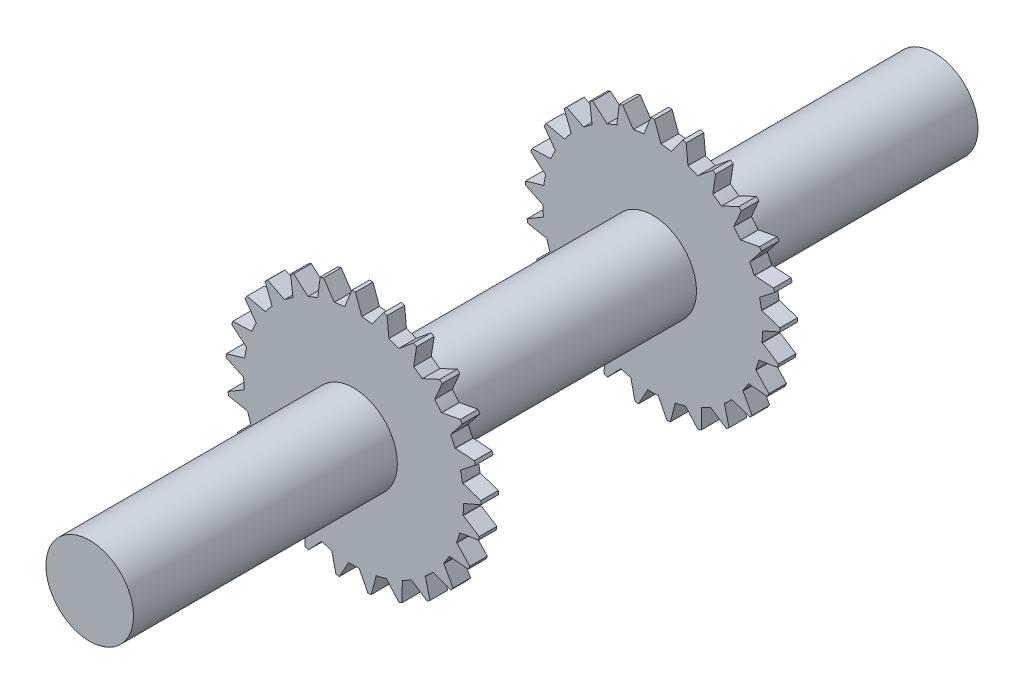
from build123d import *

# Parameters (mm, degrees)
SKETCH1_R             = 24.875
BOSS_EXTRUDE1_DEPTH   = 480
SKETCH2_R             = 62.5
BOSS_EXTRUDE2_DEPTH   = 10
BOSS_EXTRUDE3_DEPTH   = 10
CIRPATTERN2_COUNT     = 25
MIRROR1_COPY_1_DEPTH  = 10
MIRROR1_COPY_2_DEPTH  = 10
MIRROR1_COPY_3_DEPTH  = 10
MIRROR1_COPY_4_DEPTH  = 10
MIRROR1_COPY_5_DEPTH  = 10
MIRROR1_COPY_6_DEPTH  = 10
MIRROR1_COPY_7_DEPTH  = 10
MIRROR1_COPY_8_DEPTH  = 10
MIRROR1_COPY_9_DEPTH  = 10
MIRROR1_COPY_10_DEPTH = 10
MIRROR1_COPY_11_DEPTH = 10
MIRROR1_COPY_12_DEPTH = 10
MIRROR1_COPY_13_DEPTH = 10
MIRROR1_COPY_14_DEPTH = 10
MIRROR1_COPY_15_DEPTH = 10
MIRROR1_COPY_16_DEPTH = 10
MIRROR1_COPY_17_DEPTH = 10
MIRROR1_COPY_18_DEPTH = 10
MIRROR1_COPY_19_DEPTH = 10
MIRROR1_COPY_20_DEPTH = 10
MIRROR1_COPY_21_DEPTH = 10
MIRROR1_COPY_22_DEPTH = 10
MIRROR1_COPY_23_DEPTH = 10
MIRROR1_COPY_24_DEPTH = 10


with BuildPart() as part:
    # Sketch1 → Boss-Extrude1 (new body)
    with BuildSketch(Plane.XY):
        Circle(SKETCH1_R)
    extrude(amount=BOSS_EXTRUDE1_DEPTH)

    # Sketch2 → Boss-Extrude2 (add)
    with BuildSketch(Plane.XY.offset(330)):
        Circle(SKETCH2_R)
    boss_extrude2 = extrude(amount=-BOSS_EXTRUDE2_DEPTH)

    # Sketch4 → Boss-Extrude3 (add)
    with BuildSketch(Plane.XY.offset(330)):
        Polygon((-5, 62.5), (-1, 72.5), (1, 72.5), (5, 61.442173314), (5, 52.5), (-5, 52.5), align=None)
    boss_extrude3 = extrude(amount=-BOSS_EXTRUDE3_DEPTH)

    # CirPattern2: Boss-Extrude3 ×25 about axis
    cirpattern2_axis = Axis((0, 0, 0), (0, 0, 1))
    for i in range(1, CIRPATTERN2_COUNT):
        add(boss_extrude3.rotate(cirpattern2_axis, i * 360 / CIRPATTERN2_COUNT))

    # Mirror1: Boss-Extrude3, Boss-Extrude2 across plane
    add(boss_extrude3.mirror(Plane.XY.offset(240)))
    add(boss_extrude2.mirror(Plane.XY.offset(240)))

    # Mirror1 copy 1 sketch → Mirror1 copy 1 (add)
    with BuildSketch(Plane(origin=(0, 0, 150), x_dir=(0.968583161, 0.248689887, 0), z_dir=(0, 0, -1))):
        Polygon((-5, -62.5), (-1, -72.5), (1, -72.5), (5, -61.442173314), (5, -52.5), (-5, -52.5), align=None)
    extrude(amount=-MIRROR1_COPY_1_DEPTH)

    # Mirror1 copy 2 sketch → Mirror1 copy 2 (add)
    with BuildSketch(Plane(origin=(0, 0, 150), x_dir=(0.87630668, 0.481753674, 0), z_dir=(0, 0, -1))):
        Polygon((-5, -62.5), (-1, -72.5), (1, -72.5), (5, -61.442173314), (5, -52.5), (-5, -52.5), align=None)
    extrude(amount=-MIRROR1_COPY_2_DEPTH)

    # Mirror1 copy 3 sketch → Mirror1 copy 3 (add)
    with BuildSketch(Plane(origin=(0, 0, 150), x_dir=(0.728968627, 0.684547106, 0), z_dir=(0, 0, -1))):
        Polygon((-5, -62.5), (-1, -72.5), (1, -72.5), (5, -61.442173314), (5, -52.5), (-5, -52.5), align=None)
    extrude(amount=-MIRROR1_COPY_3_DEPTH)

    # Mirror1 copy 4 sketch → Mirror1 copy 4 (add)
    with BuildSketch(Plane(origin=(0, 0, 150), x_dir=(0.535826795, 0.844327926, 0), z_dir=(0, 0, -1))):
        Polygon((-5, -62.5), (-1, -72.5), (1, -72.5), (5, -61.442173314), (5, -52.5), (-5, -52.5), align=None)
    extrude(amount=-MIRROR1_COPY_4_DEPTH)

    # Mirror1 copy 5 sketch → Mirror1 copy 5 (add)
    with BuildSketch(Plane(origin=(0, 0, 150), x_dir=(0.309016994, 0.951056516, 0), z_dir=(0, 0, -1))):
        Polygon((-5, -62.5), (-1, -72.5), (1, -72.5), (5, -61.442173314), (5, -52.5), (-5, -52.5), align=None)
    extrude(amount=-MIRROR1_COPY_5_DEPTH)

    # Mirror1 copy 6 sketch → Mirror1 copy 6 (add)
    with BuildSketch(Plane(origin=(0, 0, 150), x_dir=(0.06279052, 0.998026728, 0), z_dir=(0, 0, -1))):
        Polygon((-5, -62.5), (-1, -72.5), (1, -72.5), (5, -61.442173314), (5, -52.5), (-5, -52.5), align=None)
    extrude(amount=-MIRROR1_COPY_6_DEPTH)

    # Mirror1 copy 7 sketch → Mirror1 copy 7 (add)
    with BuildSketch(Plane(origin=(0, 0, 150), x_dir=(-0.187381315, 0.982287251, 0), z_dir=(0, 0, -1))):
        Polygon((-5, -62.5), (-1, -72.5), (1, -72.5), (5, -61.442173314), (5, -52.5), (-5, -52.5), align=None)
    extrude(amount=-MIRROR1_COPY_7_DEPTH)

    # Mirror1 copy 8 sketch → Mirror1 copy 8 (add)
    with BuildSketch(Plane(origin=(0, 0, 150), x_dir=(-0.425779292, 0.904827052, 0), z_dir=(0, 0, -1))):
        Polygon((-5, -62.5), (-1, -72.5), (1, -72.5), (5, -61.442173314), (5, -52.5), (-5, -52.5), align=None)
    extrude(amount=-MIRROR1_COPY_8_DEPTH)

    # Mirror1 copy 9 sketch → Mirror1 copy 9 (add)
    with BuildSketch(Plane(origin=(0, 0, 150), x_dir=(-0.63742399, 0.770513243, 0), z_dir=(0, 0, -1))):
        Polygon((-5, -62.5), (-1, -72.5), (1, -72.5), (5, -61.442173314), (5, -52.5), (-5, -52.5), align=None)
    extrude(amount=-MIRROR1_COPY_9_DEPTH)

    # Mirror1 copy 10 sketch → Mirror1 copy 10 (add)
    with BuildSketch(Plane(origin=(0, 0, 150), x_dir=(-0.809016994, 0.587785252, 0), z_dir=(0, 0, -1))):
        Polygon((-5, -62.5), (-1, -72.5), (1, -72.5), (5, -61.442173314), (5, -52.5), (-5, -52.5), align=None)
    extrude(amount=-MIRROR1_COPY_10_DEPTH)

    # Mirror1 copy 11 sketch → Mirror1 copy 11 (add)
    with BuildSketch(Plane(origin=(0, 0, 150), x_dir=(-0.929776486, 0.368124553, 0), z_dir=(0, 0, -1))):
        Polygon((-5, -62.5), (-1, -72.5), (1, -72.5), (5, -61.442173314), (5, -52.5), (-5, -52.5), align=None)
    extrude(amount=-MIRROR1_COPY_11_DEPTH)

    # Mirror1 copy 12 sketch → Mirror1 copy 12 (add)
    with BuildSketch(Plane(origin=(0, 0, 150), x_dir=(-0.992114701, 0.125333234, 0), z_dir=(0, 0, -1))):
        Polygon((-5, -62.5), (-1, -72.5), (1, -72.5), (5, -61.442173314), (5, -52.5), (-5, -52.5), align=None)
    extrude(amount=-MIRROR1_COPY_12_DEPTH)

    # Mirror1 copy 13 sketch → Mirror1 copy 13 (add)
    with BuildSketch(Plane(origin=(0, 0, 150), x_dir=(-0.992114701, -0.125333234, 0), z_dir=(0, 0, -1))):
        Polygon((-5, -62.5), (-1, -72.5), (1, -72.5), (5, -61.442173314), (5, -52.5), (-5, -52.5), align=None)
    extrude(amount=-MIRROR1_COPY_13_DEPTH)

    # Mirror1 copy 14 sketch → Mirror1 copy 14 (add)
    with BuildSketch(Plane(origin=(0, 0, 150), x_dir=(-0.929776486, -0.368124553, 0), z_dir=(0, 0, -1))):
        Polygon((-5, -62.5), (-1, -72.5), (1, -72.5), (5, -61.442173314), (5, -52.5), (-5, -52.5), align=None)
    extrude(amount=-MIRROR1_COPY_14_DEPTH)

    # Mirror1 copy 15 sketch → Mirror1 copy 15 (add)
    with BuildSketch(Plane(origin=(0, 0, 150), x_dir=(-0.809016994, -0.587785252, 0), z_dir=(0, 0, -1))):
        Polygon((-5, -62.5), (-1, -72.5), (1, -72.5), (5, -61.442173314), (5, -52.5), (-5, -52.5), align=None)
    extrude(amount=-MIRROR1_COPY_15_DEPTH)

    # Mirror1 copy 16 sketch → Mirror1 copy 16 (add)
    with BuildSketch(Plane(origin=(0, 0, 150), x_dir=(-0.63742399, -0.770513243, 0), z_dir=(0, 0, -1))):
        Polygon((-5, -62.5), (-1, -72.5), (1, -72.5), (5, -61.442173314), (5, -52.5), (-5, -52.5), align=None)
    extrude(amount=-MIRROR1_COPY_16_DEPTH)

    # Mirror1 copy 17 sketch → Mirror1 copy 17 (add)
    with BuildSketch(Plane(origin=(0, 0, 150), x_dir=(-0.425779292, -0.904827052, 0), z_dir=(0, 0, -1))):
        Polygon((-5, -62.5), (-1, -72.5), (1, -72.5), (5, -61.442173314), (5, -52.5), (-5, -52.5), align=None)
    extrude(amount=-MIRROR1_COPY_17_DEPTH)

    # Mirror1 copy 18 sketch → Mirror1 copy 18 (add)
    with BuildSketch(Plane(origin=(0, 0, 150), x_dir=(-0.187381315, -0.982287251, 0), z_dir=(0, 0, -1))):
        Polygon((-5, -62.5), (-1, -72.5), (1, -72.5), (5, -61.442173314), (5, -52.5), (-5, -52.5), align=None)
    extrude(amount=-MIRROR1_COPY_18_DEPTH)

    # Mirror1 copy 19 sketch → Mirror1 copy 19 (add)
    with BuildSketch(Plane(origin=(0, 0, 150), x_dir=(0.06279052, -0.998026728, 0), z_dir=(0, 0, -1))):
        Polygon((-5, -62.5), (-1, -72.5), (1, -72.5), (5, -61.442173314), (5, -52.5), (-5, -52.5), align=None)
    extrude(amount=-MIRROR1_COPY_19_DEPTH)

    # Mirror1 copy 20 sketch → Mirror1 copy 20 (add)
    with BuildSketch(Plane(origin=(0, 0, 150), x_dir=(0.309016994, -0.951056516, 0), z_dir=(0, 0, -1))):
        Polygon((-5, -62.5), (-1, -72.5), (1, -72.5), (5, -61.442173314), (5, -52.5), (-5, -52.5), align=None)
    extrude(amount=-MIRROR1_COPY_20_DEPTH)

    # Mirror1 copy 21 sketch → Mirror1 copy 21 (add)
    with BuildSketch(Plane(origin=(0, 0, 150), x_dir=(0.535826795, -0.844327926, 0), z_dir=(0, 0, -1))):
        Polygon((-5, -62.5), (-1, -72.5), (1, -72.5), (5, -61.442173314), (5, -52.5), (-5, -52.5), align=None)
    extrude(amount=-MIRROR1_COPY_21_DEPTH)

    # Mirror1 copy 22 sketch → Mirror1 copy 22 (add)
    with BuildSketch(Plane(origin=(0, 0, 150), x_dir=(0.728968627, -0.684547106, 0), z_dir=(0, 0, -1))):
        Polygon((-5, -62.5), (-1, -72.5), (1, -72.5), (5, -61.442173314), (5, -52.5), (-5, -52.5), align=None)
    extrude(amount=-MIRROR1_COPY_22_DEPTH)

    # Mirror1 copy 23 sketch → Mirror1 copy 23 (add)
    with BuildSketch(Plane(origin=(0, 0, 150), x_dir=(0.87630668, -0.481753674, 0), z_dir=(0, 0, -1))):
        Polygon((-5, -62.5), (-1, -72.5), (1, -72.5), (5, -61.442173314), (5, -52.5), (-5, -52.5), align=None)
    extrude(amount=-MIRROR1_COPY_23_DEPTH)

    # Mirror1 copy 24 sketch → Mirror1 copy 24 (add)
    with BuildSketch(Plane(origin=(0, 0, 150), x_dir=(0.968583161, -0.248689887, 0), z_dir=(0, 0, -1))):
        Polygon((-5, -62.5), (-1, -72.5), (1, -72.5), (5, -61.442173314), (5, -52.5), (-5, -52.5), align=None)
    extrude(amount=-MIRROR1_COPY_24_DEPTH)


solid = part.part
